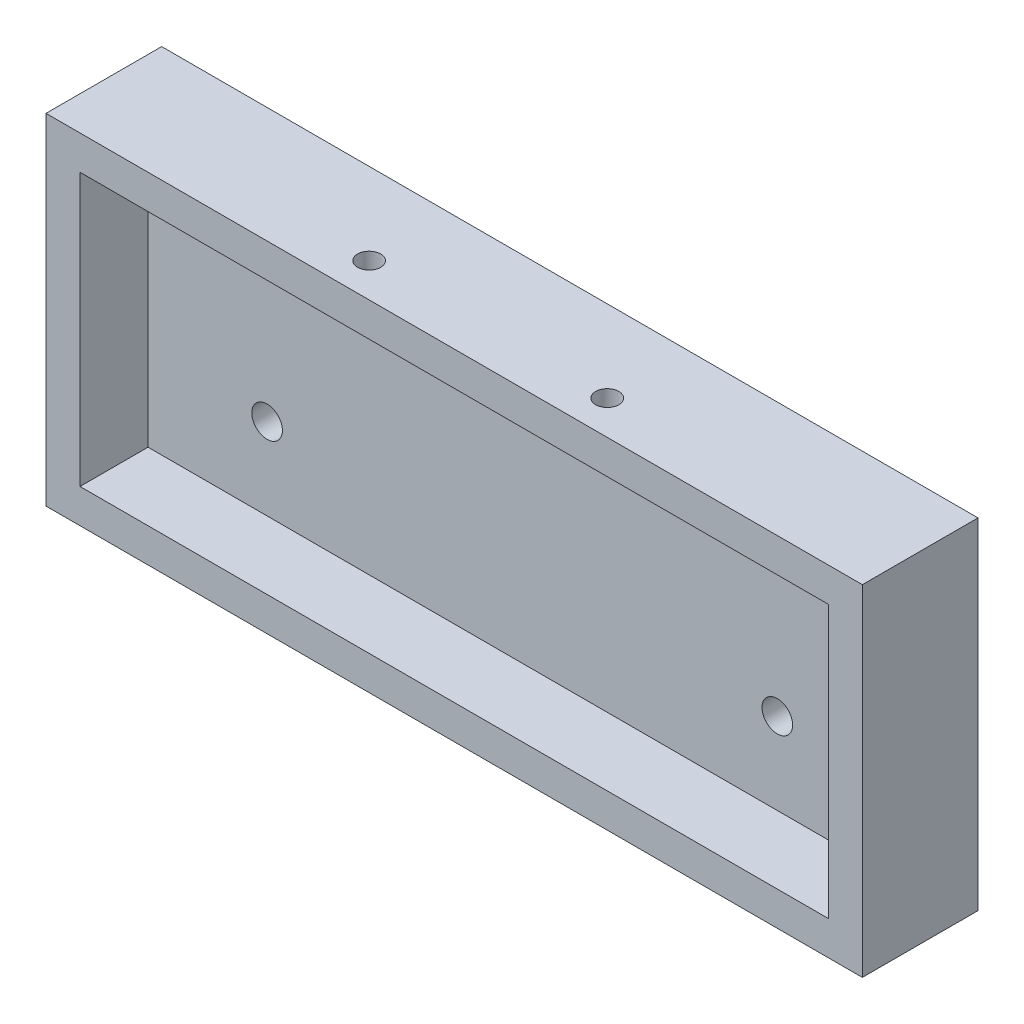
from build123d import *

# Parameters (mm, degrees)
SKETCH2_W                                       = 120
SKETCH2_H                                       = 50
BOSS_EXTRUDE3_DEPTH                             = 17
SKETCH4_W                                       = 110
SKETCH4_H                                       = 40
CUT_EXTRUDE1_DEPTH                              = 10
CSK_FOR_M3_FLAT_HEAD_MACHINE_SCREW1_D           = 3.4
CSK_FOR_M3_FLAT_HEAD_MACHINE_SCREW1_DEPTH       = 5
CSK_FOR_M3_FLAT_HEAD_MACHINE_SCREW1_CSINK_D     = 6.3
CSK_FOR_M3_FLAT_HEAD_MACHINE_SCREW1_CSINK_ANGLE = 90
CSK_FOR_M4_FLAT_HEAD_MACHINE_SCREW3_D           = 4.5
CSK_FOR_M4_FLAT_HEAD_MACHINE_SCREW3_CSINK_D     = 9.4
CSK_FOR_M4_FLAT_HEAD_MACHINE_SCREW3_CSINK_ANGLE = 90


with BuildPart() as part:
    # Sketch2 → Boss-Extrude3 (new body)
    with BuildSketch(Plane.XY):
        with Locations((60, 25)):
            Rectangle(SKETCH2_W, SKETCH2_H)
    extrude(amount=BOSS_EXTRUDE3_DEPTH)

    # Sketch4 → Cut-Extrude1 (cut)
    with BuildSketch(Plane.XY.offset(17)):
        with Locations((60, 25)):
            Rectangle(SKETCH4_W, SKETCH4_H)
    extrude(amount=-CUT_EXTRUDE1_DEPTH, mode=Mode.SUBTRACT)

    # CSK for M3 Flat Head Machine Screw1
    with Locations(Plane(origin=(0, 45, 0), x_dir=(-1, 0, 0), z_dir=(0, -1, 0))):
        with Locations((-42.5, -12), (-77.5, -12)):
            CounterSinkHole(CSK_FOR_M3_FLAT_HEAD_MACHINE_SCREW1_D / 2, CSK_FOR_M3_FLAT_HEAD_MACHINE_SCREW1_CSINK_D / 2, depth=CSK_FOR_M3_FLAT_HEAD_MACHINE_SCREW1_DEPTH, counter_sink_angle=CSK_FOR_M3_FLAT_HEAD_MACHINE_SCREW1_CSINK_ANGLE)

    # CSK for M4 Flat Head Machine Screw3 (through all)
    with Locations(Plane(origin=(0, 0, 0), x_dir=(-1, 0, 0), z_dir=(0, 0, -1))):
        with Locations((-97.5, 17), (-22.5, 17)):
            CounterSinkHole(CSK_FOR_M4_FLAT_HEAD_MACHINE_SCREW3_D / 2, CSK_FOR_M4_FLAT_HEAD_MACHINE_SCREW3_CSINK_D / 2, counter_sink_angle=CSK_FOR_M4_FLAT_HEAD_MACHINE_SCREW3_CSINK_ANGLE)


solid = part.part
